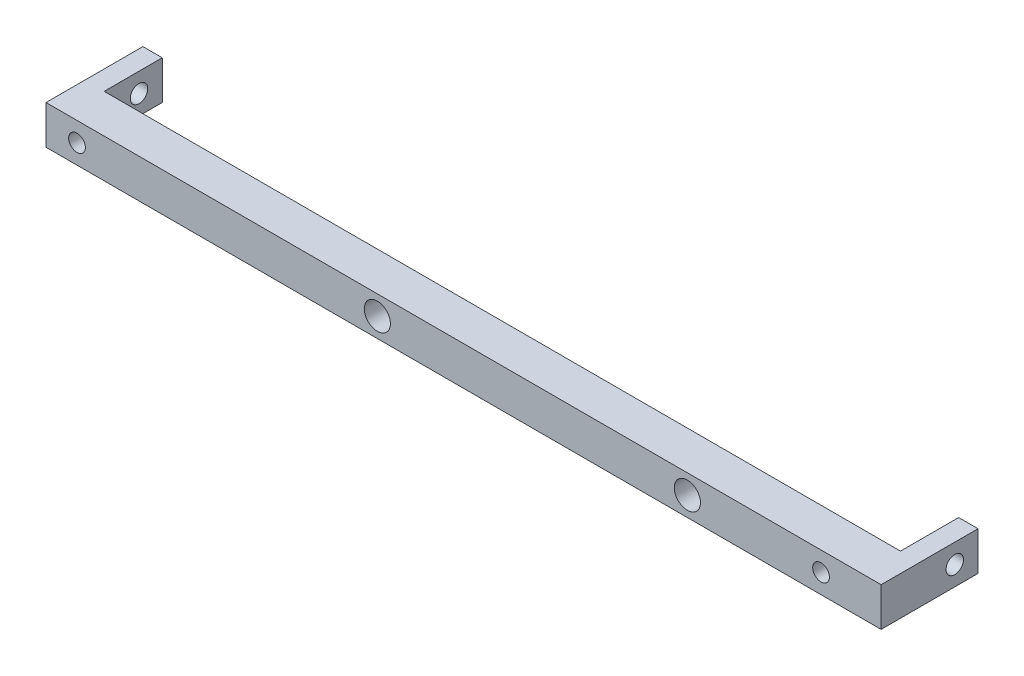
from build123d import *

# Parameters (mm, degrees)
SKETCH1_W                              = 215.5
SKETCH1_H                              = 25
BOSS_EXTRUDE1_DEPTH                    = 10
SKETCH2_W                              = 205.5
SKETCH2_H                              = 15
CUT_EXTRUDE1_DEPTH                     = 11
SKETCH3_W                              = 70
SKETCH3_H                              = 7
CUT_EXTRUDE2_DEPTH                     = 8.5
SKETCH4_W                              = 54.75
SKETCH4_H                              = 7
CUT_EXTRUDE3_DEPTH                     = 8.5
SKETCH5_W                              = 19.25
SKETCH5_H                              = 7
CUT_EXTRUDE4_DEPTH                     = 8.5
F_4_5_4_5_DIAMETER_HOLE1_D             = 4.5
F_4_5_4_5_DIAMETER_HOLE1_DEPTH         = 5
M4_CLEARANCE_HOLE1_D                   = 4.31
TAPPED_HOLE_FOR_1_4_20_HELICOIL1_D     = 6.7564
TAPPED_HOLE_FOR_1_4_20_HELICOIL1_DEPTH = 20.523
TAPPED_HOLE_FOR_1_4_20_HELICOIL1_TIP   = 2.029827343
F_4_5_4_5_DIAMETER_HOLE2_D             = 4.5
F_4_5_4_5_DIAMETER_HOLE2_DEPTH         = 215.5
FILLET1_R                              = 3


with BuildPart() as part:
    # Sketch1 → Boss-Extrude1 (new body)
    with BuildSketch(Plane(origin=(0, 5, 0), x_dir=(1, 0, 0), z_dir=(0, 1, 0))):
        with Locations((0, 10.5)):
            Rectangle(SKETCH1_W, SKETCH1_H)
    extrude(amount=-BOSS_EXTRUDE1_DEPTH)

    # Sketch2 → Cut-Extrude1 (cut, through all)
    with BuildSketch(Plane.XZ.offset(5)):
        with Locations((0, -15.5)):
            Rectangle(SKETCH2_W, SKETCH2_H)
    extrude(amount=-CUT_EXTRUDE1_DEPTH, mode=Mode.SUBTRACT)

    # Sketch3 → Cut-Extrude2 (cut)
    with BuildSketch(Plane(origin=(0, 0, -8), x_dir=(-1, 0, 0), z_dir=(0, 0, -1))):
        with Locations((-17.75, 0)):
            Rectangle(SKETCH3_W, SKETCH3_H)
    extrude(amount=-CUT_EXTRUDE2_DEPTH, mode=Mode.SUBTRACT)

    # Sketch4 → Cut-Extrude3 (cut)
    with BuildSketch(Plane(origin=(0, 0, -8), x_dir=(-1, 0, 0), z_dir=(0, 0, -1))):
        with Locations((54.625, 0)):
            Rectangle(SKETCH4_W, SKETCH4_H)
    extrude(amount=-CUT_EXTRUDE3_DEPTH, mode=Mode.SUBTRACT)

    # Sketch5 → Cut-Extrude4 (cut)
    with BuildSketch(Plane(origin=(0, 0, -8), x_dir=(-1, 0, 0), z_dir=(0, 0, -1))):
        with Locations((-72.375, 0)):
            Rectangle(SKETCH5_W, SKETCH5_H)
    extrude(amount=-CUT_EXTRUDE4_DEPTH, mode=Mode.SUBTRACT)

    # Ø4.5 (4.5) Diameter Hole1
    with Locations(Plane(origin=(-102.75, 0, 0), x_dir=(0, 0, -1), z_dir=(1, 0, 0))):
        with Locations((17, 0)):
            Hole(F_4_5_4_5_DIAMETER_HOLE1_D / 2, depth=F_4_5_4_5_DIAMETER_HOLE1_DEPTH)

    # M4 Clearance Hole1 (through all)
    with Locations(Plane.XY.offset(2)):
        with Locations((-99.75154, 0), (92.2496, 0)):
            Hole(M4_CLEARANCE_HOLE1_D / 2)

    # Tapped Hole for 1/4-20 Helicoil1
    with Locations(Plane.XY.offset(2)):
        with Locations((57.75, 0), (-22.25, 0)):
            Hole(TAPPED_HOLE_FOR_1_4_20_HELICOIL1_D / 2, depth=TAPPED_HOLE_FOR_1_4_20_HELICOIL1_DEPTH)
            with Locations((0, 0, -(TAPPED_HOLE_FOR_1_4_20_HELICOIL1_DEPTH + TAPPED_HOLE_FOR_1_4_20_HELICOIL1_TIP / 2))):  # 118° drill point
                Cone(0, TAPPED_HOLE_FOR_1_4_20_HELICOIL1_D / 2, TAPPED_HOLE_FOR_1_4_20_HELICOIL1_TIP, mode=Mode.SUBTRACT)

    # Ø4.5 (4.5) Diameter Hole2
    with Locations(Plane(origin=(107.75, 0, 0), x_dir=(0, 0, -1), z_dir=(1, 0, 0))):
        with Locations((17, 0)):
            Hole(F_4_5_4_5_DIAMETER_HOLE2_D / 2, depth=F_4_5_4_5_DIAMETER_HOLE2_DEPTH)

    # Fillet1
    fillet1_edges = [part.edges().sort_by_distance(p)[0] for p in [
        (-17.25, 3.5, -3.75),
        (-17.25, -3.5, -3.75),
        (52.75, -3.5, -3.75),
        (52.75, 3.5, -3.75),
        (-82, 3.5, -3.75),
        (-82, -3.5, -3.75),
        (-27.25, -3.5, -3.75),
        (-27.25, 3.5, -3.75),
        (62.75, -3.5, -3.75),
        (82, -3.5, -3.75),
        (82, 3.5, -3.75),
        (62.75, 3.5, -3.75),
    ]]
    fillet(fillet1_edges, radius=FILLET1_R)


solid = part.part
